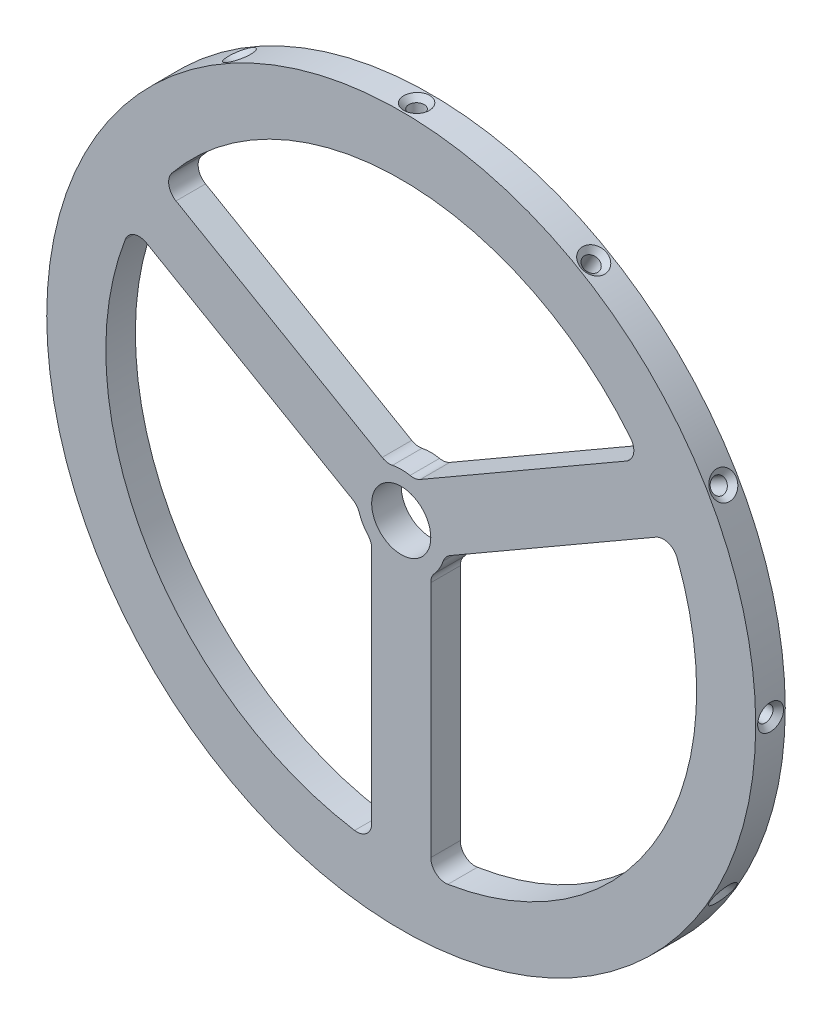
from build123d import *

# Parameters (mm, degrees)
SKETCH1_R           = 60
SKETCH1_R_2         = 5
BOSS_EXTRUDE1_DEPTH = 5
CIRPATTERN2_COUNT   = 12


with BuildPart() as part:
    # Sketch1 → Boss-Extrude1 (new body)
    with BuildSketch(Plane.XY):
        Circle(SKETCH1_R)
        Circle(SKETCH1_R_2, mode=Mode.SUBTRACT)
        with BuildLine():
            ThreePointArc((5, -46.904157598), (5.877785789, -48.806372374), (7.894736842, -49.372797472))
            ThreePointArc((7.894736842, -49.372797472), (43.301270189, -25), (46.705465288, 17.849356074))
            ThreePointArc((46.705465288, 17.849356074), (45.206451237, 19.312874376), (43.120192023, 19.12195178))
            Line((43.120192023, 19.12195178), (8.228219619, -1.02293788))
            ThreePointArc((8.228219619, -1.02293788), (7.543486141, -1.60471166), (7.108664714, -2.391001042))
            ThreePointArc((7.108664714, -2.391001042), (6.495190528, -3.75), (5.625, -4.960783708))
            ThreePointArc((5.625, -4.960783708), (5.161464133, -5.730494801), (5, -6.614378278))
            Line((5, -6.614378278), (5, -46.904157598))
        make_face(mode=Mode.SUBTRACT)
        with BuildLine():
            ThreePointArc((-3.228219619, 7.637316158), (-2.382022007, 7.335206461), (-1.483664714, 7.35178475))
            ThreePointArc((-1.483664714, 7.35178475), (0, 7.5), (1.483664714, 7.35178475))
            ThreePointArc((1.483664714, 7.35178475), (2.382022007, 7.335206461), (3.228219619, 7.637316158))
            Line((3.228219619, 7.637316158), (38.120192023, 27.782205818))
            ThreePointArc((38.120192023, 27.782205818), (39.328665448, 29.493497998), (38.810728445, 31.523441397))
            ThreePointArc((38.810728445, 31.523441397), (0, 50), (-38.810728445, 31.523441397))
            ThreePointArc((-38.810728445, 31.523441397), (-39.328665448, 29.493497998), (-38.120192023, 27.782205818))
            Line((-38.120192023, 27.782205818), (-3.228219619, 7.637316158))
        make_face(mode=Mode.SUBTRACT)
        with BuildLine():
            Line((-5, -6.614378278), (-5, -46.904157598))
            ThreePointArc((-5, -46.904157598), (-5.877785789, -48.806372374), (-7.894736842, -49.372797472))
            ThreePointArc((-7.894736842, -49.372797472), (-43.301270189, -25), (-46.705465288, 17.849356074))
            ThreePointArc((-46.705465288, 17.849356074), (-45.206451237, 19.312874376), (-43.120192023, 19.12195178))
            Line((-43.120192023, 19.12195178), (-8.228219619, -1.02293788))
            ThreePointArc((-8.228219619, -1.02293788), (-7.543486141, -1.60471166), (-7.108664714, -2.391001042))
            ThreePointArc((-7.108664714, -2.391001042), (-6.495190528, -3.75), (-5.625, -4.960783708))
            ThreePointArc((-5.625, -4.960783708), (-5.161464133, -5.730494801), (-5, -6.614378278))
        make_face(mode=Mode.SUBTRACT)
    extrude(amount=BOSS_EXTRUDE1_DEPTH)

    # Sketch9 → CSK for M2 Flat Head Machine Screw2 (revolve, cut)
    with BuildSketch(Plane(origin=(-0.076214321, -59.999951595, 2.477524755), x_dir=(0.999999193, -0.001270239, 0), z_dir=(0, 0, 1))):
        Polygon((0, 0), (0, 5.781118805), (1.3, 5), (1.3, 0.9), (2.2, 0), align=None)
    csk_for_m2_flat_head_machine_screw2 = revolve(axis=Axis((-0.084280337, -66.349946472, 2.477524755), (0.001270239, 0.999999193, 0)), mode=Mode.SUBTRACT)

    # CirPattern2: CSK for M2 Flat Head Machine Screw2 ×12 about axis
    cirpattern2_axis = Axis((0, 0, 5), (0, 0, 1))
    for i in range(1, CIRPATTERN2_COUNT):
        add(csk_for_m2_flat_head_machine_screw2.rotate(cirpattern2_axis, i * 360 / CIRPATTERN2_COUNT), mode=Mode.SUBTRACT)


solid = part.part
